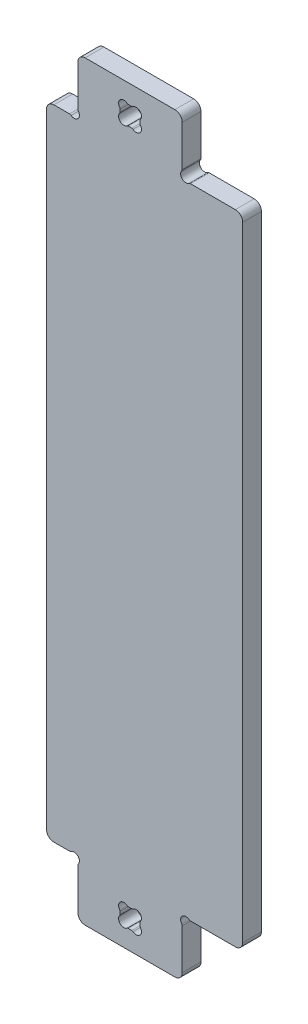
from build123d import *

# Parameters (mm, degrees)
BOSS_EXTRU_2_DEPTH      = 18
ENL_V_MAT_EXTRU_1_DEPTH = 19
CONG_1_R                = 7


with BuildPart() as part:
    # Esquisse2 → Boss.-Extru.2 (new body)
    with BuildSketch(Plane.XY):
        with BuildLine():
            Line((0, 0), (100, 0))
            Line((100, 0), (100, 46.012238509))
            ThreePointArc((100, 46.012238509), (99.874827529, 46.793387794), (99.511844635, 47.496314371))
            ThreePointArc((99.511844635, 47.496314371), (100, 54), (106.503685629, 54.488155365))
            ThreePointArc((106.503685629, 54.488155365), (107.206612206, 54.125172471), (107.987761491, 54))
            Line((107.987761491, 54), (157.994949366, 54))
            Line((157.994949366, 54), (157.994949366, 360))
            Line((157.994949366, 360), (-30, 360))
            Line((-30, 360), (-30, 54))
            Line((-30, 54), (-7.987761491, 54))
            ThreePointArc((-7.987761491, 54), (-7.206612206, 54.125172471), (-6.503685629, 54.488155365))
            ThreePointArc((-6.503685629, 54.488155365), (0, 54), (0.488155365, 47.496314371))
            ThreePointArc((0.488155365, 47.496314371), (0.125172471, 46.793387794), (0, 46.012238509))
            Line((0, 46.012238509), (0, 0))
        make_face()
    extrude(amount=BOSS_EXTRU_2_DEPTH)

    # Esquisse1 → Enlèv. mat.-Extru.1 (cut, through all)
    with BuildSketch(Plane.XY):
        with BuildLine():
            Line((59.5, 28.248771852), (59.5, 25.751228148))
            ThreePointArc((59.5, 25.751228148), (59.599672829, 25.160561143), (59.88765279, 24.635309084))
            ThreePointArc((59.88765279, 24.635309084), (59.5, 18), (52.864690916, 17.61234721))
            ThreePointArc((52.864690916, 17.61234721), (52.339438857, 17.900327171), (51.748771852, 18))
            Line((51.748771852, 18), (48.251228148, 18))
            ThreePointArc((48.251228148, 18), (47.660561143, 17.900327171), (47.135309084, 17.61234721))
            ThreePointArc((47.135309084, 17.61234721), (40.5, 18), (40.11234721, 24.635309084))
            ThreePointArc((40.11234721, 24.635309084), (40.400327171, 25.160561143), (40.5, 25.751228148))
            Line((40.5, 25.751228148), (40.5, 28.248771852))
            ThreePointArc((40.5, 28.248771852), (40.400327171, 28.839438857), (40.11234721, 29.364690916))
            ThreePointArc((40.11234721, 29.364690916), (40.5, 36), (47.135309084, 36.38765279))
            ThreePointArc((47.135309084, 36.38765279), (47.660561143, 36.099672829), (48.251228148, 36))
            Line((48.251228148, 36), (51.748771852, 36))
            ThreePointArc((51.748771852, 36), (52.339438857, 36.099672829), (52.864690916, 36.38765279))
            ThreePointArc((52.864690916, 36.38765279), (59.5, 36), (59.88765279, 29.364690916))
            ThreePointArc((59.88765279, 29.364690916), (59.599672829, 28.839438857), (59.5, 28.248771852))
        make_face()
    extrude(amount=ENL_V_MAT_EXTRU_1_DEPTH, mode=Mode.SUBTRACT)

    # Congé1
    cong_1_edges = [part.edges().sort_by_distance(p)[0] for p in [
        (-30, 54, 9),
        (157.994949366, 54, 9),
        (100, 0, 9),
        (0, 0, 9),
    ]]
    fillet(cong_1_edges, radius=CONG_1_R)

    # Symétrie1: part across plane


with BuildPart() as part_1:
    add(part.part)
    add(part.part.mirror(Plane(origin=(157.994949366, 360, 18), x_dir=(0, 0, 1), z_dir=(0, -1, 0))))


solid = part_1.part
